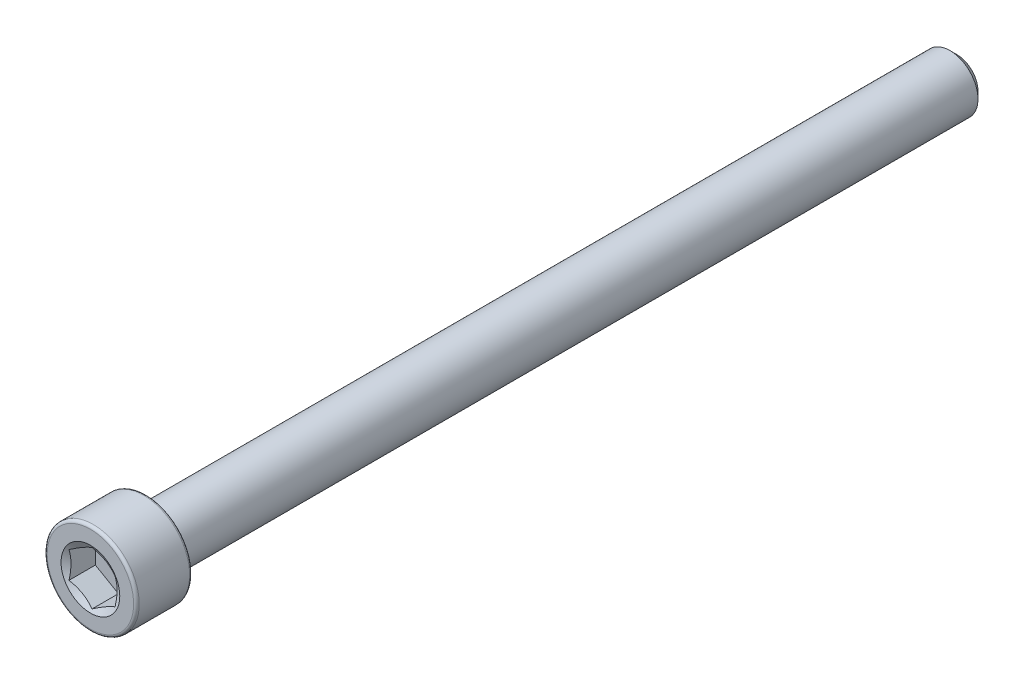
from build123d import *

# Parameters (mm, degrees)
CUT_EXTRUDE1_START = 37.338
CUT_EXTRUDE1_DEPTH = 2.413


with BuildPart() as part:
    # Sketch2 → Revolve1 (revolve)
    with BuildSketch(Plane(origin=(0, 0, 0), x_dir=(0, 0, -1), z_dir=(1, 0, 0)), mode=Mode.PRIVATE) as revolve1_sk:
        with BuildLine():
            Line((37.338, 0), (37.338, 1.8176875))
            Line((37.338, 1.8176875), (36.7426875, 2.413))
            Line((36.7426875, 2.413), (-32.512, 2.413))
            Line((-32.512, 2.413), (-32.512, 3.72745))
            ThreePointArc((-32.512, 3.72745), (-32.582675134, 3.898074866), (-32.7533, 3.96875))
            Line((-32.7533, 3.96875), (-37.0967, 3.96875))
            ThreePointArc((-37.0967, 3.96875), (-37.267324866, 3.898074866), (-37.338, 3.72745))
            Line((-37.338, 3.72745), (-37.338, 0))
            Line((-37.338, 0), (37.338, 0))
        make_face()
    revolve(revolve1_sk.sketch.rotate(Axis((0, 0, -37.338), (0, 0, 1)), 90), axis=Axis((0, 0, -37.338), (0, 0, 1)))

    # Sketch3 → Cut-Extrude1 (cut)
    with BuildSketch(Plane.XY.offset(CUT_EXTRUDE1_START)):
        Polygon((-1.984375, 1.14567944), (-1.984375, -1.14567944), (0, -2.291358881), (1.984375, -1.14567944), (1.984375, 1.14567944), (0, 2.291358881), align=None)
    extrude(amount=-CUT_EXTRUDE1_DEPTH, mode=Mode.SUBTRACT)

    # Cut-Extrude2 cone 1 section (through the dimple's axis) → Cut-Extrude2 (revolve, cut)
    with BuildSketch(Plane(origin=(0, 0, 37.338), x_dir=(0, -1, 0), z_dir=(1, 0, 0))):
        Polygon((0, 0), (2.530707401, 0), (0, 1.461104599), align=None)
    revolve(axis=Axis((0, 0, 37.338), (0, 0, -1)), mode=Mode.SUBTRACT)


solid = part.part
